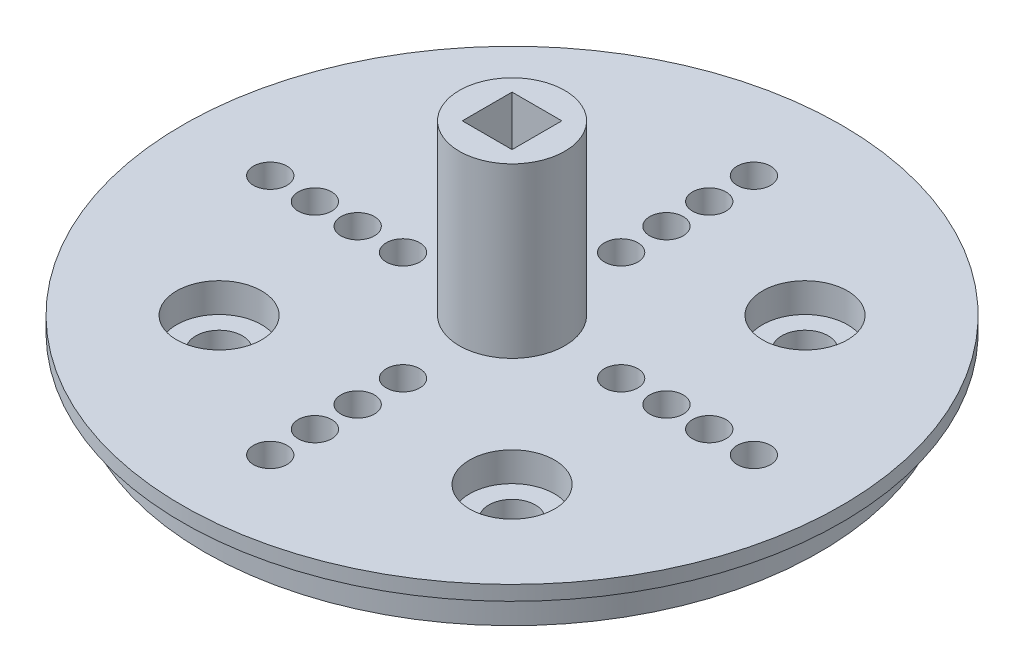
from build123d import *

# Parameters (mm, degrees)
SKETCH2_R           = 21
BOSS_EXTRUDE1_DEPTH = 3.5
SKETCH4_R           = 5.5
SKETCH4_R_2         = 1.143
SKETCH4_R_3         = 1.5875
CUT_EXTRUDE2_DEPTH  = 4.5
SKETCH5_R           = 2.9
CUT_EXTRUDE4_DEPTH  = 2
SKETCH6_W           = 2.148549125
SKETCH6_H           = 1
SKETCH8_R           = 3.6
SKETCH8_W           = 3.4
SKETCH8_H           = 3.4
BOSS_EXTRUDE3_DEPTH = 15
SKETCH7_R           = 6.25
BOSS_EXTRUDE4_DEPTH = 2.5


with BuildPart() as part:
    # Sketch2 → Boss-Extrude1 (new body)
    with BuildSketch(Plane(origin=(0, 0, 0), x_dir=(1, 0, 0), z_dir=(0, 1, 0))):
        Circle(SKETCH2_R)
    extrude(amount=BOSS_EXTRUDE1_DEPTH)

    # Sketch4 → Cut-Extrude2 (cut, through all)
    with BuildSketch(Plane(origin=(0, 3.5, 0), x_dir=(1, 0, 0), z_dir=(0, 1, 0))):
        Circle(SKETCH4_R)
        with Locations((7.445, 0)):
            Circle(SKETCH4_R_2)
        with Locations((10.54, 0)):
            Circle(SKETCH4_R_2)
        with Locations((13.46, 0)):
            Circle(SKETCH4_R_2)
        with Locations((16.51, 0)):
            Circle(SKETCH4_R_2)
        with Locations((10, 10)):
            Circle(SKETCH4_R_3)
        with Locations((0, -7.445)):
            Circle(SKETCH4_R_2)
        with Locations((0, -10.54)):
            Circle(SKETCH4_R_2)
        with Locations((0, -13.46)):
            Circle(SKETCH4_R_2)
        with Locations((0, -16.51)):
            Circle(SKETCH4_R_2)
        with Locations((10, -10)):
            Circle(SKETCH4_R_3)
        with Locations((-7.445, 0)):
            Circle(SKETCH4_R_2)
        with Locations((-10.54, 0)):
            Circle(SKETCH4_R_2)
        with Locations((-13.46, 0)):
            Circle(SKETCH4_R_2)
        with Locations((-16.51, 0)):
            Circle(SKETCH4_R_2)
        with Locations((-10, -10)):
            Circle(SKETCH4_R_3)
        with Locations((0, 7.445)):
            Circle(SKETCH4_R_2)
        with Locations((0, 10.54)):
            Circle(SKETCH4_R_2)
        with Locations((0, 13.46)):
            Circle(SKETCH4_R_2)
        with Locations((0, 16.51)):
            Circle(SKETCH4_R_2)
        with Locations((-10, 10)):
            Circle(SKETCH4_R_3)
    extrude(amount=-CUT_EXTRUDE2_DEPTH, mode=Mode.SUBTRACT)

    # Sketch5 → Cut-Extrude4 (cut)
    with BuildSketch(Plane(origin=(0, 3.5, 0), x_dir=(1, 0, 0), z_dir=(0, 1, 0))):
        with Locations((-10, 10)):
            Circle(SKETCH5_R)
        with Locations((-10, -10)):
            Circle(SKETCH5_R)
        with Locations((10, 10)):
            Circle(SKETCH5_R)
        with Locations((10, -10)):
            Circle(SKETCH5_R)
    extrude(amount=-CUT_EXTRUDE4_DEPTH, mode=Mode.SUBTRACT)

    # Sketch6 → Revolve1 (revolve)
    with BuildSketch(Plane.XY):
        with Locations((-21.425725437, 3)):
            Rectangle(SKETCH6_W, SKETCH6_H)
    revolve(axis=Axis((0, 0, 0), (0, 1, 0)))



with BuildPart() as body_2:
    # Sketch8 → Boss-Extrude3 (new body)
    with BuildSketch(Plane(origin=(0, 0, 0), x_dir=(1, 0, 0), z_dir=(0, 1, 0))):
        Circle(SKETCH8_R)
        Rectangle(SKETCH8_W, SKETCH8_H, mode=Mode.SUBTRACT)
    extrude(amount=BOSS_EXTRUDE3_DEPTH)


with BuildPart() as part_1:
    add(part.part)

    add(body_2.part)  # Boss-Extrude4 merges body 2
    # Sketch7 → Boss-Extrude4 (add)
    with BuildSketch(Plane(origin=(0, 3.5, 0), x_dir=(1, 0, 0), z_dir=(0, 1, 0))):
        Circle(SKETCH7_R)
    extrude(amount=-BOSS_EXTRUDE4_DEPTH)


solid = part_1.part
